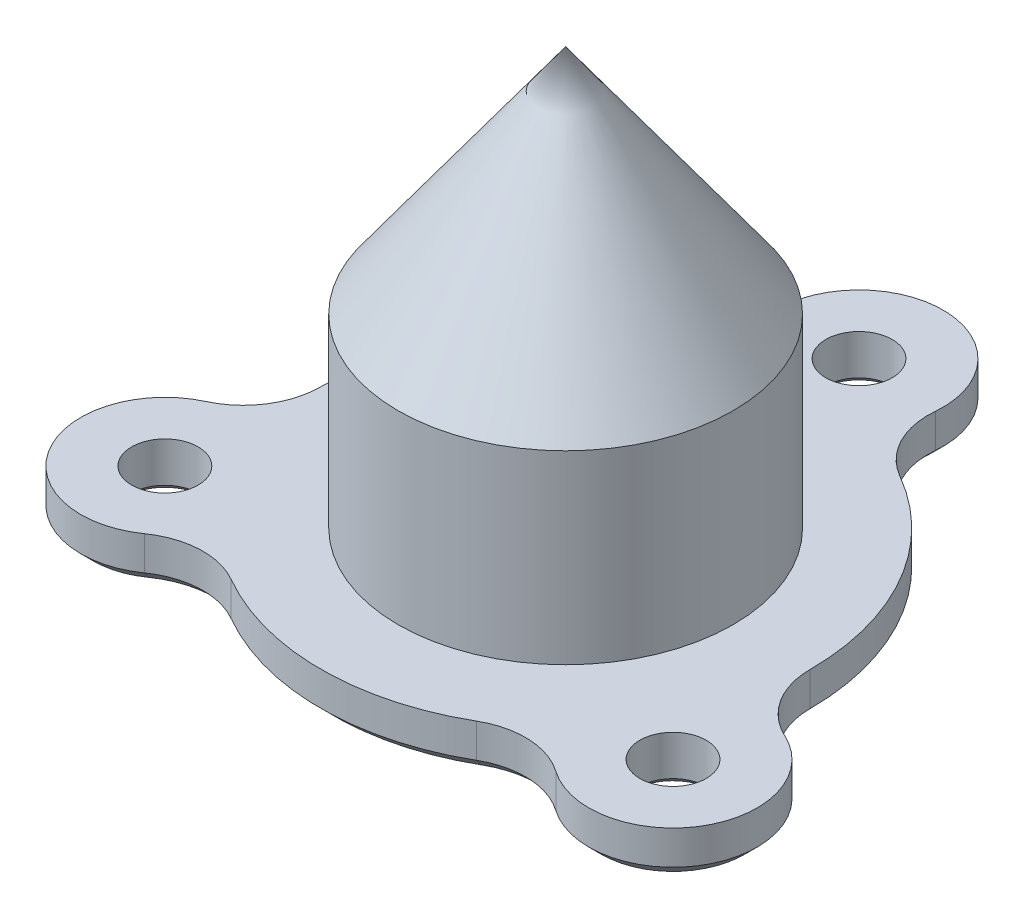
from build123d import *

# Parameters (mm, degrees)
SKETCH1_R           = 10.85
SKETCH1_R_2         = 2.15
BOSS_EXTRUDE1_DEPTH = 3
SKETCH1_2_R         = 10.85
BOSS_EXTRUDE2_DEPTH = 15
CHAMFER1_SIZE       = 0.8
CHAMFER2_SIZE       = 0.4


with BuildPart() as part:
    # Sketch1 → Boss-Extrude1 (new body)
    with BuildSketch(Plane(origin=(0, 0, 0), x_dir=(1, 0, 0), z_dir=(0, 1, 0))):
        with BuildLine():
            ThreePointArc((5.42820267, 18.513054646), (0, 24.45), (-5.42820267, 18.513054646))
            ThreePointArc((-5.42820267, 18.513054646), (-5.97168494, 15.760391094), (-7.912232668, 13.73386596))
            ThreePointArc((-7.912232668, 13.73386596), (-13.72650265, 7.925), (-15.849993148, -0.014738489))
            ThreePointArc((-15.849993148, -0.014738489), (-16.634741531, -2.708564686), (-18.74687696, -4.555565914))
            ThreePointArc((-18.74687696, -4.555565914), (-21.174321123, -12.225), (-13.31867429, -13.957488732))
            ThreePointArc((-13.31867429, -13.957488732), (-10.663056591, -13.051826408), (-7.937760479, -13.719127471))
            ThreePointArc((-7.937760479, -13.719127471), (0, -15.85), (7.937760479, -13.719127471))
            ThreePointArc((7.937760479, -13.719127471), (10.663056591, -13.051826408), (13.31867429, -13.957488732))
            ThreePointArc((13.31867429, -13.957488732), (21.174321123, -12.225), (18.74687696, -4.555565914))
            ThreePointArc((18.74687696, -4.555565914), (16.634741531, -2.708564686), (15.849993148, -0.014738489))
            ThreePointArc((15.849993148, -0.014738489), (13.72650265, 7.925), (7.912232668, 13.73386596))
            ThreePointArc((7.912232668, 13.73386596), (5.97168494, 15.760391094), (5.42820267, 18.513054646))
        make_face()
        Circle(SKETCH1_R, mode=Mode.SUBTRACT)
        with Locations((0, 19)):
            Circle(SKETCH1_R_2, mode=Mode.SUBTRACT)
        with Locations((16.454482672, -9.5)):
            Circle(SKETCH1_R_2, mode=Mode.SUBTRACT)
        with Locations((-16.454482672, -9.5)):
            Circle(SKETCH1_R_2, mode=Mode.SUBTRACT)
    extrude(amount=BOSS_EXTRUDE1_DEPTH)

    # Sketch1_2 → Boss-Extrude2 (add)
    with BuildSketch(Plane(origin=(0, 0, 0), x_dir=(1, 0, 0), z_dir=(0, 1, 0))):
        Circle(SKETCH1_2_R)
    extrude(amount=BOSS_EXTRUDE2_DEPTH)

    # Sketch2 → Revolve1 (revolve)
    with BuildSketch(Plane.XY):
        Polygon((0, 15), (10.85, 15), (0, 30), align=None)
    revolve(axis=Axis((0, 18.413549721, 0), (0, -1, 0)))

    # Chamfer1
    chamfer1_edges = [part.edges().sort_by_distance(p)[0] for p in [
        (0, 0, -24.45),
        (-5.97168494, 0, -15.760391094),
        (5.97168494, 0, -15.760391094),
        (-13.72650265, 0, -7.925),
        (13.72650265, 0, -7.925),
        (-16.634741531, 0, 2.708564686),
        (16.634741531, 0, 2.708564686),
        (-21.174321123, 0, 12.225),
        (21.174321123, 0, 12.225),
        (-10.663056591, 0, 13.051826408),
        (10.663056591, 0, 13.051826408),
        (0, 0, 15.85),
    ]]
    chamfer(chamfer1_edges, length=CHAMFER1_SIZE)

    # Chamfer2
    chamfer2_edges = [part.edges().sort_by_distance(p)[0] for p in [
        (-18.604482672, 0, 9.5),
        (14.304482672, 0, 9.5),
        (-2.15, 0, -19),
    ]]
    chamfer(chamfer2_edges, length=CHAMFER2_SIZE)


solid = part.part
